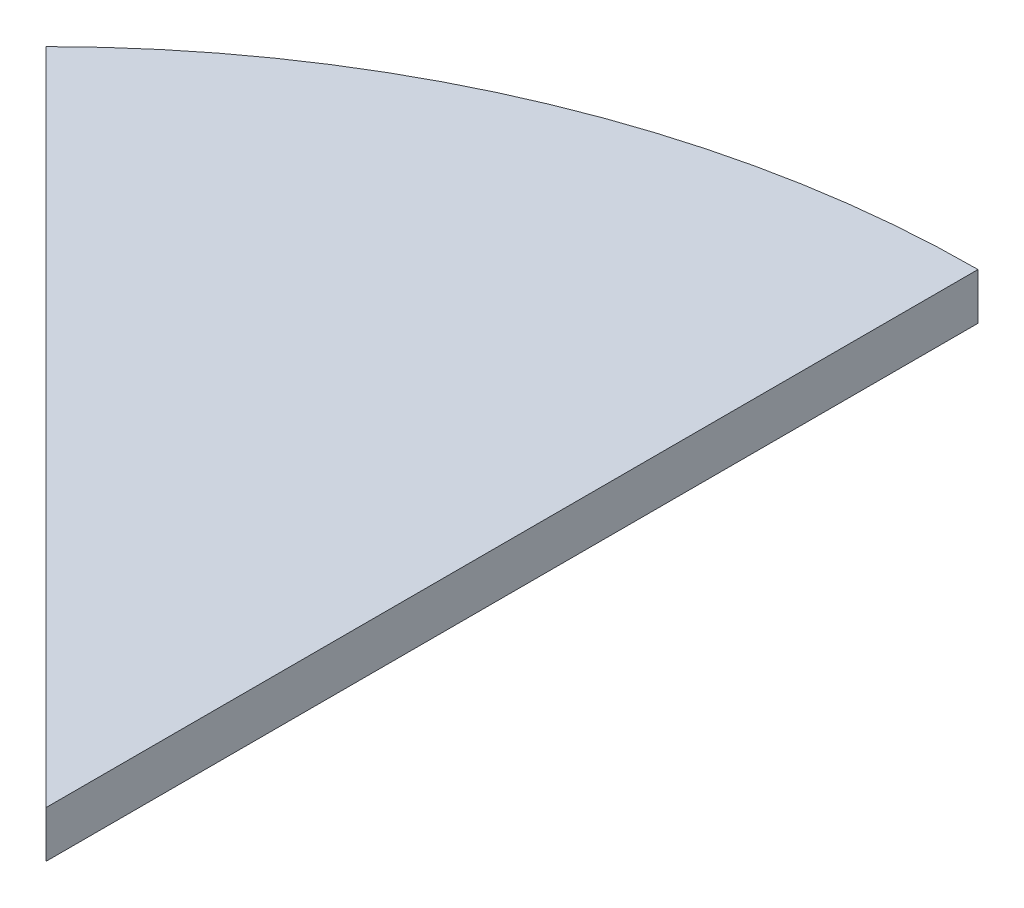
from build123d import *

# Parameters (mm, degrees)
EXTRUDE1_DEPTH = 20


with BuildPart() as part:
    # Sketch1 → Extrude1 (new body)
    with BuildSketch(Plane(origin=(0, 0, 0), x_dir=(1, 0, 0), z_dir=(0, 1, 0))):
        with BuildLine():
            Line((0, 400), (0, 0))
            Line((0, 0), (-282.842712475, 282.842712475))
            ThreePointArc((-282.842712475, 282.842712475), (-153.073372946, 369.551813005), (0, 400))
        make_face()
    extrude(amount=EXTRUDE1_DEPTH)


solid = part.part
